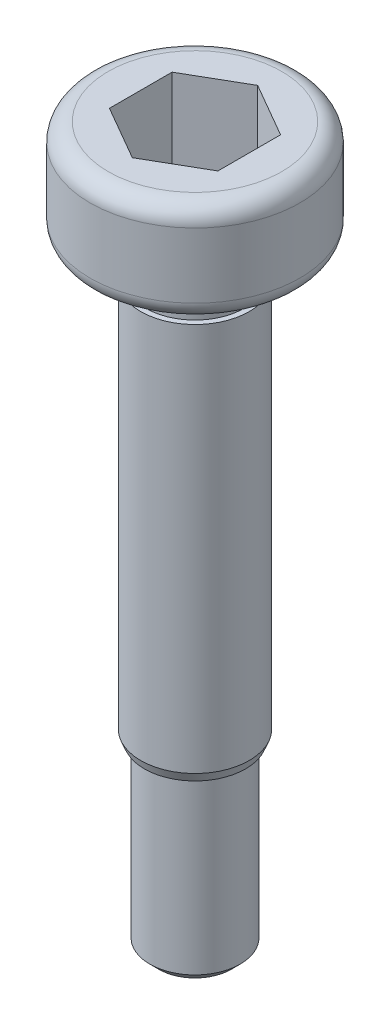
from build123d import *

# Parameters (mm, degrees)
SKETCH_2_R          = 1.25
EXTRUDE_1_DEPTH     = 4.75
SKETCH_3_R          = 1.25
EXTRUDE_2_DEPTH     = 0.25
EXTRUDE_2_TAPER     = 45
CUT_EXTRUDE_1_DEPTH = 2.4
FILLET_1_R          = 0.5


with BuildPart() as part:
    # 草图1 → 旋转1 (revolve)
    with BuildSketch(Plane(origin=(0, 0, 0), x_dir=(-1, 0, 0), z_dir=(0, 0, -1))):
        Polygon((-1.4, -14.8), (0, -14.8), (0, 0), (-2.9, 0), (-2.9, -2.8), (-1.35, -2.8), (-1.35, -3.8), (-1.5, -3.8), (-1.5, -14.55), align=None)
    revolve(axis=Axis((0, -14.8, 0), (0, 1, 0)))

    # 草图2 → 凸台-拉伸1 (add)
    with BuildSketch(Plane.XZ.offset(14.8)):
        Circle(SKETCH_2_R)
    extrude(amount=EXTRUDE_1_DEPTH)

    # 草图3 → 凸台-拉伸2 (add)
    with BuildSketch(Plane.XZ.offset(19.55)):
        Circle(SKETCH_3_R)
    extrude(amount=EXTRUDE_2_DEPTH, taper=EXTRUDE_2_TAPER)

    # 草图4 → 切除-拉伸1 (cut)
    with BuildSketch(Plane(origin=(0, 0, 0), x_dir=(-1, 0, 0), z_dir=(0, 1, 0))):
        Polygon((-1.5, 0.866025404), (-1.5, -0.866025404), (0, -1.732050808), (1.5, -0.866025404), (1.5, 0.866025404), (0, 1.732050808), align=None)
    extrude(amount=-CUT_EXTRUDE_1_DEPTH, mode=Mode.SUBTRACT)

    # 圆角1
    fillet_1_edges = [part.edges().sort_by_distance(p)[0] for p in [
        (-2.9, -2.8, 0),
        (-2.9, 0, 0),
    ]]
    fillet(fillet_1_edges, radius=FILLET_1_R)


solid = part.part
